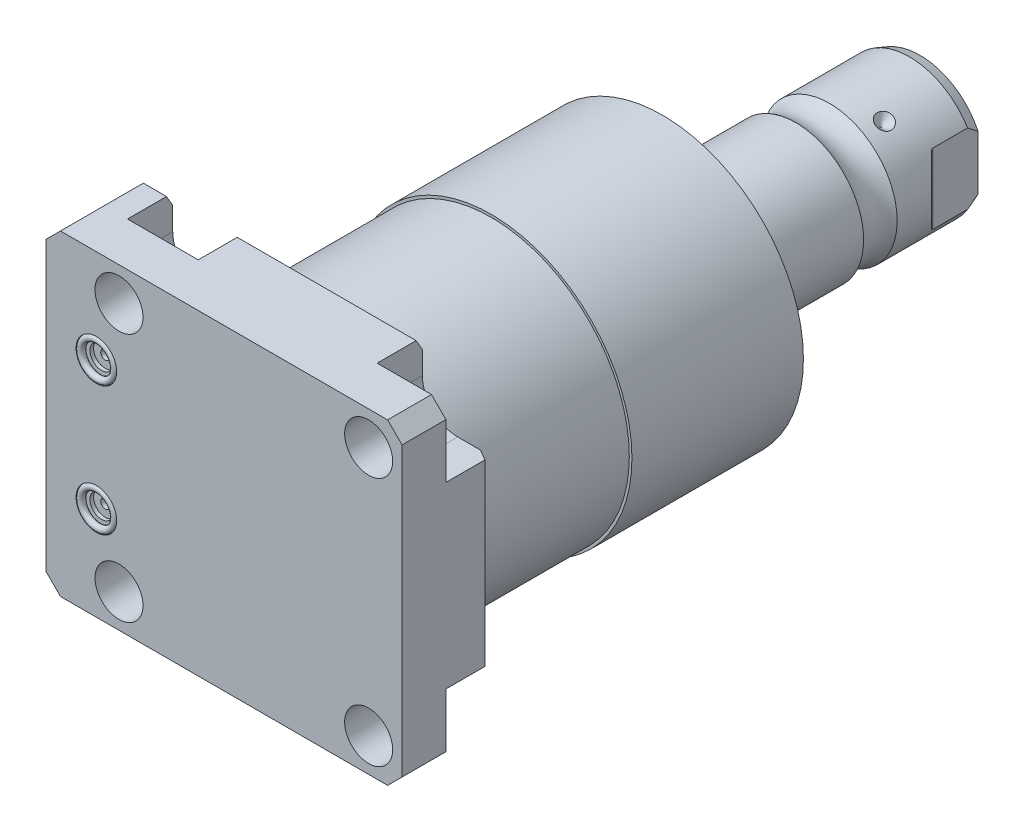
from build123d import *

# Parameters (mm, degrees)
SKETCH1_W               = 100
SKETCH1_H               = 88.9
EXTRUDE1_DEPTH          = 25.019
HOLE1_D                 = 13.487
CUT_EXTRUDE2_DEPTH      = 12.7
SKETCH6_R               = 5.7023
CUT_EXTRUDE3_DEPTH      = 1.4478
SKETCH7_R               = 3.2512
CUT_EXTRUDE4_DEPTH      = 1.016
SKETCH8_R               = 1.2446
CUT_EXTRUDE5_DEPTH      = 11.9888
SKETCH9_R               = 0.9271
CHAMFER1_SIZE           = 4.064
CHAMFER2_SIZE           = 3.0226
CHAMFER2_SIZE2          = 1.745098924
CIRPATTERN1_COUNT       = 3
CUT_EXTRUDE8_DEPTH      = 45.45
CUT_EXTRUDE8_DEPTH_BACK = 45.45


with BuildPart() as part:
    # Sketch1 → Extrude1 (new body)
    with BuildSketch(Plane.XY):
        with Locations((-5.55, 0)):
            Rectangle(SKETCH1_W, SKETCH1_H)
    extrude(amount=EXTRUDE1_DEPTH)

    # Hole1 (through all)
    with Locations(Plane(origin=(0, 0, 0), x_dir=(-1, 0, 0), z_dir=(0, 0, -1))):
        with Locations((-35.052, -35.052), (-35.052, 35.052), (35.052, 35.052), (35.052, -35.052)):
            Hole(HOLE1_D / 2)

    # Sketch3 → Cut-Extrude2 (cut)
    with BuildSketch(Plane(origin=(0, 0, 0), x_dir=(-1, 0, 0), z_dir=(0, 0, -1))):
        with BuildLine():
            Line((-35.052, -25.1205), (-44.45, -25.1205))
            Line((-44.45, -25.1205), (-44.45, -44.45))
            Line((-44.45, -44.45), (-25.1205, -44.45))
            Line((-25.1205, -44.45), (-25.1205, -35.052))
            ThreePointArc((-25.1205, -35.052), (-28.029369003, -28.029369003), (-35.052, -25.1205))
        make_face()
        with BuildLine():
            Line((-44.45, 25.1205), (-44.45, 44.45))
            Line((-44.45, 44.45), (-25.1205, 44.45))
            Line((-25.1205, 44.45), (-25.1205, 35.052))
            ThreePointArc((-25.1205, 35.052), (-28.029369003, 28.029369003), (-35.052, 25.1205))
            Line((-35.052, 25.1205), (-44.45, 25.1205))
        make_face()
        with BuildLine():
            Line((25.1205, 44.45), (25.1205, 35.052))
            ThreePointArc((25.1205, 35.052), (35.052, 25.1205), (44.9835, 35.052))
            Line((44.9835, 35.052), (44.9835, 44.45))
            Line((44.9835, 44.45), (25.1205, 44.45))
        make_face()
        with BuildLine():
            Line((44.9835, -44.45), (25.1205, -44.45))
            Line((25.1205, -44.45), (25.1205, -35.052))
            ThreePointArc((25.1205, -35.052), (35.052, -25.1205), (44.9835, -35.052))
            Line((44.9835, -35.052), (44.9835, -44.45))
        make_face()
    extrude(amount=-CUT_EXTRUDE2_DEPTH, mode=Mode.SUBTRACT)

    # Sketch23 → Cut-Revolve5 (revolve, cut)
    with BuildSketch(Plane.XY.offset(12.014), mode=Mode.PRIVATE) as cut_revolve5_sk:
        Polygon((-55.55, -23.749), (-55.296, -23.749), (-55.296, -19.6596), (-54.5848, -18.9484), (-41.1228, -18.9484), (-41.1228, -13.0048), (-55.55, -13.0048), align=None)
    cut_revolve5 = revolve(cut_revolve5_sk.sketch.rotate(Axis((-11.939660979, -13.0048, 12.014), (-1, 0, 0)), 180), axis=Axis((-11.939660979, -13.0048, 12.014), (-1, 0, 0)), mode=Mode.SUBTRACT)  # turned: the seam where the file's is

    # Mirror1: Cut-Revolve5 across plane
    add(cut_revolve5.mirror(Plane.ZX), mode=Mode.SUBTRACT)

    # Sketch6 → Cut-Extrude3 (cut)
    with BuildSketch(Plane.XY.offset(25.019)):
        with Locations((-41.402, -18.11)):
            Circle(SKETCH6_R)
        with Locations((-41.402, 18.11)):
            Circle(SKETCH6_R)
    extrude(amount=-CUT_EXTRUDE3_DEPTH, mode=Mode.SUBTRACT)

    # Sketch7 → Cut-Extrude4 (cut)
    with BuildSketch(Plane.XY.offset(23.5712)):
        with Locations((-41.402, 18.11)):
            Circle(SKETCH7_R)
        with Locations((-41.402, -18.11)):
            Circle(SKETCH7_R)
    extrude(amount=-CUT_EXTRUDE4_DEPTH, mode=Mode.SUBTRACT)

    # Sketch8 → Cut-Extrude5 (cut)
    with BuildSketch(Plane.XY.offset(22.5552)):
        with Locations((-41.402, 18.11)):
            Circle(SKETCH8_R)
        with Locations((-41.402, -18.11)):
            Circle(SKETCH8_R)
    extrude(amount=-CUT_EXTRUDE5_DEPTH, mode=Mode.SUBTRACT)

    # Chamfer1
    chamfer1_edges = [part.edges().sort_by_distance(p)[0] for p in [
        (-55.55, 44.45, 12.5095),
        (44.45, 44.45, 18.8595),
        (44.45, -44.45, 18.8595),
        (-55.55, -44.45, 12.5095),
    ]]
    chamfer(chamfer1_edges, length=CHAMFER1_SIZE)

    # Chamfer2
    chamfer2_edges = [part.edges().sort_by_distance(p)[0] for p in [
        (-48.23475, -44.45, 0),
        (44.45, 0, 0),
        (0, 44.45, 0),
        (-48.23475, 44.45, 0),
        (0, -44.45, 0),
    ]]
    chamfer2_side = [part.faces().sort_by_distance(p)[0] for p in [
        (-6.590555374, 0, 0),
    ]]
    chamfer(chamfer2_edges, length=CHAMFER2_SIZE, length2=CHAMFER2_SIZE2, reference=chamfer2_side[0])

    # Sketch24 → Revolve4 (revolve)
    with BuildSketch(Plane(origin=(0, 0, 0), x_dir=(0, 0, -1), z_dir=(1, 0, 0)), mode=Mode.PRIVATE) as revolve4_sk:
        Polygon((0, 0), (0, 38.786), (44.45, 38.786), (44.45, 39.5225), (92.60888753, 39.5225), (96.393, 25.4), (96.393, 0), align=None)
    revolve(revolve4_sk.sketch.rotate(Axis((0, 0, 0), (0, 0, -1)), 90), axis=Axis((0, 0, 0), (0, 0, -1)))  # turned: the seam where the file's is

    # Sketch17 → Revolve3 (revolve)
    with BuildSketch(Plane(origin=(0, 0, 0), x_dir=(0, 0, -1), z_dir=(1, 0, 0)), mode=Mode.PRIVATE) as revolve3_sk:
        with BuildLine():
            Line((96.393, 0), (96.393, -19.05))
            Line((96.393, -19.05), (129.98990643, -19.05))
            ThreePointArc((129.98990643, -19.05), (134.697, -17.5006), (139.40409357, -19.05))
            Line((139.40409357, -19.05), (161.95099416, -19.05))
            Line((161.95099416, -19.05), (164.872, -17.98684082))
            Line((164.872, -17.98684082), (164.872, 0))
            Line((164.872, 0), (96.393, 0))
        make_face()
    revolve(revolve3_sk.sketch.rotate(Axis((0, 0, -130.8989), (0, 0, 1)), 270), axis=Axis((0, 0, -130.8989), (0, 0, 1)))  # turned: the seam where the file's is

    # Sketch28 → Cut-Revolve6 (revolve, cut)
    with BuildSketch(Plane(origin=(0, 0, 0), x_dir=(1, 0, 0), z_dir=(0, 1, 0)), mode=Mode.PRIVATE) as cut_revolve6_sk:
        Polygon((-19.05, 147.778), (-16.637, 145.365), (-19.05, 145.365), align=None)
    cut_revolve6 = revolve(cut_revolve6_sk.sketch.rotate(Axis((-34.306164512, 0, -145.365), (1, 0, 0)), 180), axis=Axis((-34.306164512, 0, -145.365), (1, 0, 0)), mode=Mode.SUBTRACT)  # turned: the seam where the file's is

    # CirPattern1: Cut-Revolve6 ×3 about axis
    cirpattern1_axis = Axis((0, 0, -130.8989), (0, 0, -1))
    for i in range(1, CIRPATTERN1_COUNT):
        add(cut_revolve6.rotate(cirpattern1_axis, i * 360 / CIRPATTERN1_COUNT), mode=Mode.SUBTRACT)

    # Sketch32 → Hole2 (revolve, cut)
    with BuildSketch(Plane(origin=(0, 0, -164.872), x_dir=(0, 1, 0), z_dir=(1, 0, 0))):
        Polygon((0, 0), (0, 29.566487704), (6.9342, 25.4), (6.9342, 0), align=None)
    revolve(axis=Axis((0, 0, -169.116199587), (0, 0, 1)), mode=Mode.SUBTRACT)

    # Sketch34 → Cut-Extrude8 (cut, two sides)
    with BuildSketch(Plane(origin=(0, 0, 0), x_dir=(0, 0, -1), z_dir=(0, 1, 0))) as cut_extrude8_sk:
        with BuildLine():
            Line((149.087868636, 19.05), (151.633183558, 16.504685078))
            ThreePointArc((151.633183558, 16.504685078), (151.880394643, 16.339503912), (152.172, 16.2815))
            Line((152.172, 16.2815), (164.872, 16.2815))
            Line((164.872, 16.2815), (164.872, 19.05))
            Line((164.872, 19.05), (149.087868636, 19.05))
        make_face()
        with BuildLine():
            Line((164.872, -19.05), (149.087868636, -19.05))
            Line((149.087868636, -19.05), (151.633183558, -16.504685078))
            ThreePointArc((151.633183558, -16.504685078), (151.880394643, -16.339503912), (152.172, -16.2815))
            Line((152.172, -16.2815), (164.872, -16.2815))
            Line((164.872, -16.2815), (164.872, -19.05))
        make_face()
    extrude(amount=CUT_EXTRUDE8_DEPTH, mode=Mode.SUBTRACT)
    extrude(cut_extrude8_sk.sketch, amount=-CUT_EXTRUDE8_DEPTH_BACK, mode=Mode.SUBTRACT)


with BuildPart() as body_2:
    # Sketch9 → Revolve1 (revolve)
    with BuildSketch(Plane(origin=(-41.656, 18.11, 23.5712), x_dir=(1, 0, 0), z_dir=(0, 1, 0))):
        with Locations((5.0292, -0.9271)):
            Circle(SKETCH9_R)
    revolve(axis=Axis((-41.402, 18.11, 25.51811), (0, 0, -1)))


with BuildPart() as body_3:
    # Mirror2: mirrored copy
    add(body_2.part.mirror(Plane.ZX))


solid = Compound([part.part, body_2.part, body_3.part])
